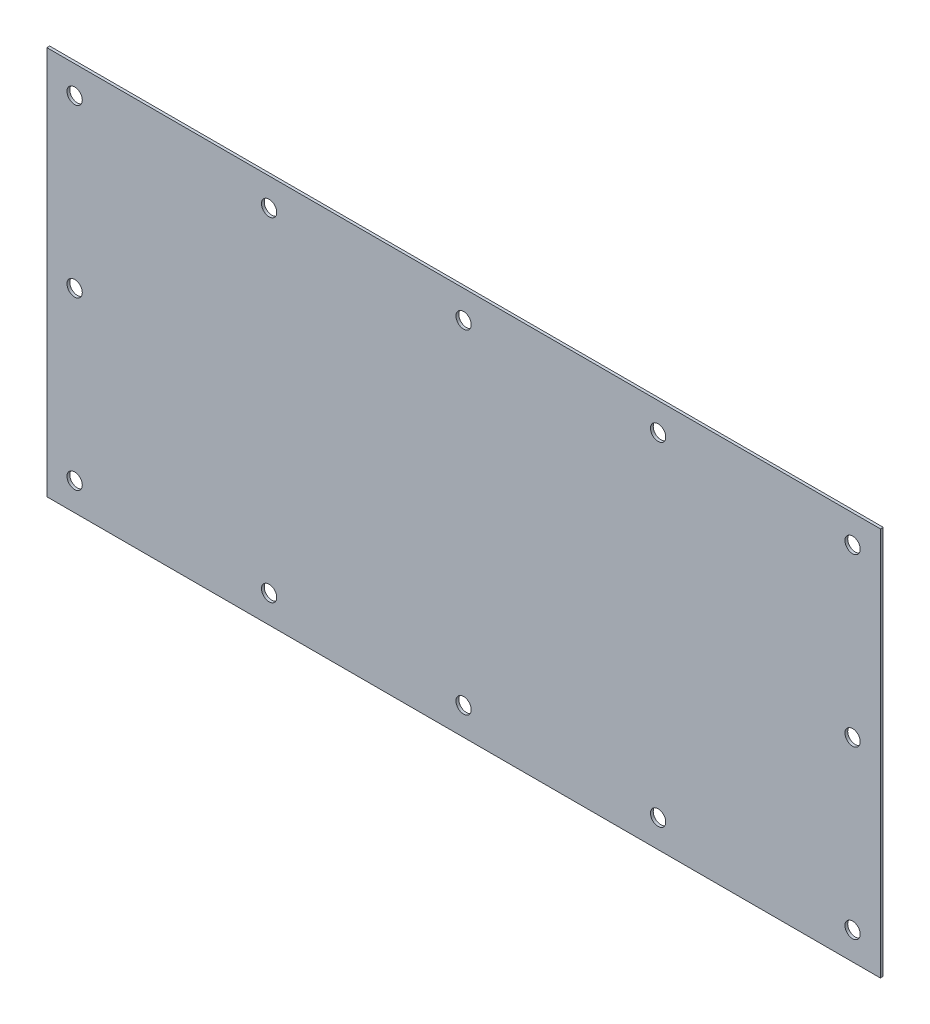
from build123d import *

# Parameters (mm, degrees)
SKETCH_1_W         = 300
SKETCH_1_H         = 140
EXTRUDE_1_DEPTH    = 1
HOLE_WIZARD_M5_1_D = 5.5


with BuildPart() as part:
    # 스케치1 → 보스-돌출1 (new body)
    with BuildSketch(Plane.XY):
        Rectangle(SKETCH_1_W, SKETCH_1_H)
    extrude(amount=EXTRUDE_1_DEPTH)

    # M5 여유 구멍1 (through all)
    with Locations(Plane(origin=(0, 0, 0), x_dir=(-1, 0, 0), z_dir=(0, 0, -1))):
        with Locations((-140, 60), (-70, 60), (70, 60), (0, 60), (140, 60), (140, 0), (140, -60), (-140, 0), (-140, -60), (-70, -60), (70, -60), (0, -60)):
            Hole(HOLE_WIZARD_M5_1_D / 2)


solid = part.part
